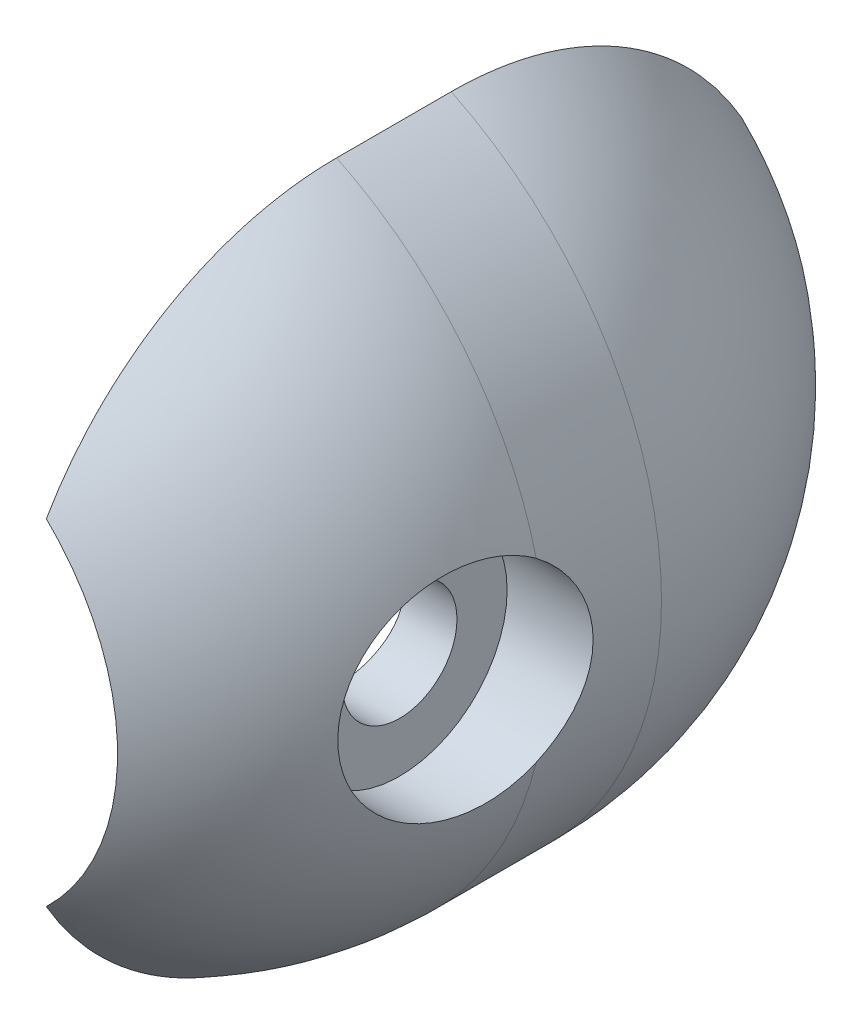
from build123d import *

# Parameters (mm, degrees)
BODY_ANGLE                  = 180
HOLE_FOR_HANDLE_DEPTH       = 7.5
SKETCH6_R                   = 1.1303
F_5_40_SET_SCREW_HOLE_DEPTH = 7
SKETCH8_R                   = 0.75
HOLE_FOR_CABLE_DEPTH        = 7
SKETCH9_R                   = 6.5
SKETCH9_R_2                 = 0.75
BOSS_EXTRUDE1_DEPTH         = 2
SKETCH10_R                  = 0.8
F_2X0_4_SCREW_HOLE_DEPTH    = 14
SKETCH11_R                  = 1
CUT_EXTRUDE5_DEPTH          = 4
SKETCH12_R                  = 1.875
CUT_EXTRUDE6_DEPTH          = 1.5
REVOLVE4_ANGLE              = 180
SKETCH14_R                  = 0.75
CUT_EXTRUDE7_DEPTH          = 7.5
SKETCH15_W                  = 12.911147491
SKETCH15_H                  = 21.852119754
CUT_EXTRUDE9_DEPTH          = 14.0000001


with BuildPart() as part:
    # Sketch3 → body (revolve)
    with BuildSketch(Plane.XY):
        with BuildLine():
            Line((0, 6.5), (0, -6.5))
            ThreePointArc((0, -6.5), (6.5, 0), (0, 6.5))
        make_face()
    revolve(axis=Axis((0, 6.5, 0), (0, -1, 0)), revolution_arc=BODY_ANGLE)

    # Sketch5 → hole for handle (cut, through all)
    with BuildSketch(Plane(origin=(0, 0, 0), x_dir=(-1, 0, 0), z_dir=(0, 0, -1))):
        with BuildLine():
            Line((1.5, 3.688881761), (1.5, 2.702827207))
            Line((1.5, 2.702827207), (-1.5, 2.702827207))
            Line((-1.5, 2.702827207), (-1.5, 3.688881761))
            Line((-1.5, 3.688881761), (-1.5, 3.788881761))
            ThreePointArc((-1.5, 3.788881761), (0, -4.075), (1.5, 3.788881761))
            Line((1.5, 3.788881761), (1.5, 3.688881761))
        make_face()
    extrude(amount=-HOLE_FOR_HANDLE_DEPTH, mode=Mode.SUBTRACT)

    # Sketch6 → 5-40 set screw hole (cut)
    with BuildSketch(Plane(origin=(0, 6.5, 0), x_dir=(1, 0, 0), z_dir=(0, 1, 0))):
        with Locations((0, -1.564027547)):
            Circle(SKETCH6_R)
    extrude(amount=-F_5_40_SET_SCREW_HOLE_DEPTH, mode=Mode.SUBTRACT)

    # Sketch8 → hole for cable (cut)
    with BuildSketch(Plane(origin=(0, 0, 0), x_dir=(-1, 0, 0), z_dir=(0, 0, -1))):
        with Locations((0, 4.237225844)):
            Circle(SKETCH8_R)
    extrude(amount=-HOLE_FOR_CABLE_DEPTH, mode=Mode.SUBTRACT)

    # Sketch9 → Boss-Extrude1 (add)
    with BuildSketch(Plane(origin=(0, 0, 0), x_dir=(-1, 0, 0), z_dir=(0, 0, -1))):
        Circle(SKETCH9_R)
        with Locations((0, 4.237225844)):
            Circle(SKETCH9_R_2, mode=Mode.SUBTRACT)
        with BuildLine():
            Line((-1.5, 2.702827207), (-1.5, 3.788881761))
            ThreePointArc((-1.5, 3.788881761), (0, -4.075), (1.5, 3.788881761))
            Line((1.5, 3.788881761), (1.5, 2.702827207))
            Line((1.5, 2.702827207), (-1.5, 2.702827207))
        make_face(mode=Mode.SUBTRACT)
    extrude(amount=BOSS_EXTRUDE1_DEPTH)

    # Sketch10 → 2X0.4 screw hole (cut, through all)
    with BuildSketch(Plane(origin=(6.5, 0, 0), x_dir=(0, 0, -1), z_dir=(1, 0, 0))):
        with Locations((-1.067713855, 0)):
            Circle(SKETCH10_R)
    extrude(amount=-F_2X0_4_SCREW_HOLE_DEPTH, mode=Mode.SUBTRACT)

    # Sketch11 → Cut-Extrude5 (cut)
    with BuildSketch(Plane(origin=(6.5, 0, 0), x_dir=(0, 0, -1), z_dir=(1, 0, 0))):
        with Locations((-1.067713855, 0)):
            Circle(SKETCH11_R)
    extrude(amount=-CUT_EXTRUDE5_DEPTH, mode=Mode.SUBTRACT)

    # Sketch12 → Cut-Extrude6 (cut)
    with BuildSketch(Plane(origin=(6.5, 0, 0), x_dir=(0, 0, -1), z_dir=(1, 0, 0))):
        with Locations((-1.067713855, 0)):
            Circle(SKETCH12_R)
    extrude(amount=-CUT_EXTRUDE6_DEPTH, mode=Mode.SUBTRACT)

    # Sketch13 → Revolve4 (revolve)
    with BuildSketch(Plane(origin=(0, 0, -2), x_dir=(-1, 0, 0), z_dir=(0, 0, -1))):
        with BuildLine():
            Line((0, 6.5), (0, -6.5))
            ThreePointArc((0, -6.5), (6.5, 0), (0, 6.5))
        make_face()
    revolve(axis=Axis((0, 6.5, -2), (0, -1, 0)), revolution_arc=REVOLVE4_ANGLE)

    # Sketch14 → Cut-Extrude7 (cut, through all)
    with BuildSketch(Plane.XY.offset(-2)):
        with Locations((0, 4.237225844)):
            Circle(SKETCH14_R)
        with BuildLine():
            Line((1.5, 3.788881761), (1.5, 2.702827207))
            Line((1.5, 2.702827207), (-1.5, 2.702827207))
            Line((-1.5, 2.702827207), (-1.5, 3.788881761))
            ThreePointArc((-1.5, 3.788881761), (0, -4.075), (1.5, 3.788881761))
        make_face()
    extrude(amount=-CUT_EXTRUDE7_DEPTH, mode=Mode.SUBTRACT)

    # Sketch15 → Cut-Extrude9 (cut, through all)
    with BuildSketch(Plane(origin=(0, 6.5, 0), x_dir=(1, 0, 0), z_dir=(0, 1, 0))):
        with Locations((-3.623390746, 1.595465377)):
            Rectangle(SKETCH15_W, SKETCH15_H)
    extrude(amount=-CUT_EXTRUDE9_DEPTH, mode=Mode.SUBTRACT)


solid = part.part
